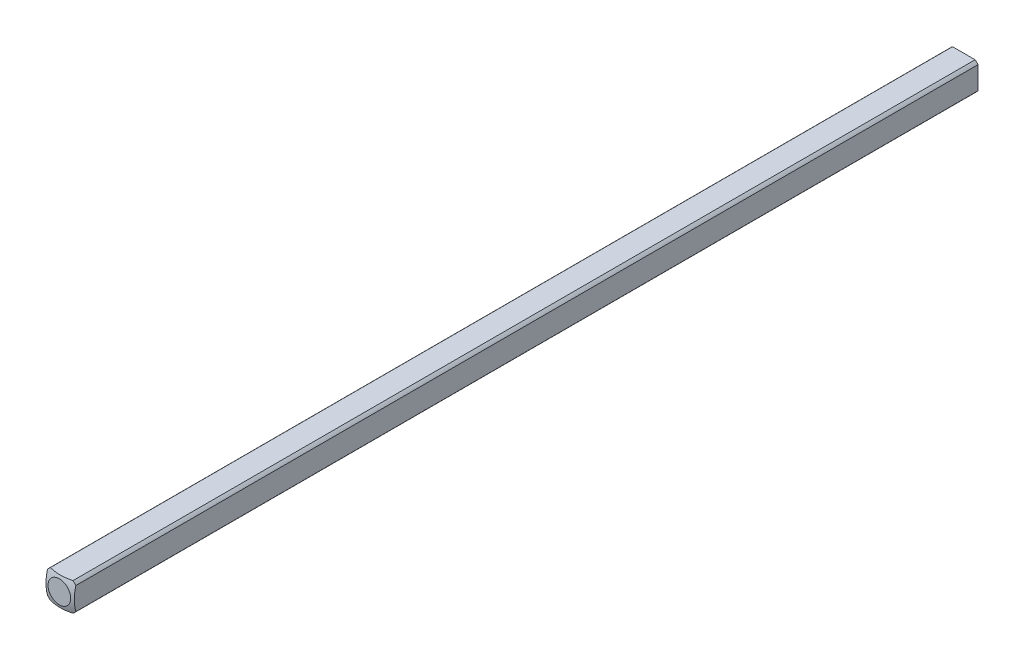
from build123d import *

# Parameters (mm, degrees)
SKETCH1_W           = 3.175
SKETCH1_H           = 3.175
BOSS_EXTRUDE1_DEPTH = 152.4
SKETCH2_OUTSIDE_W   = 35.668
SKETCH2_OUTSIDE_H   = 35.668
SKETCH2_OUTSIDE_R   = 2.032
CUT_EXTRUDE1_DEPTH  = 153.4
CUT_EXTRUDE2_DEPTH  = 4.175


with BuildPart() as part:
    # Sketch1 → Boss-Extrude1 (new body)
    with BuildSketch(Plane.XY):
        Rectangle(SKETCH1_W, SKETCH1_H)
    extrude(amount=BOSS_EXTRUDE1_DEPTH)

    # Sketch2 outside → Cut-Extrude1 (cut, through all)
    with BuildSketch(Plane(origin=(0, 0, 0), x_dir=(-1, 0, 0), z_dir=(0, 0, -1))):
        Rectangle(SKETCH2_OUTSIDE_W, SKETCH2_OUTSIDE_H)
        Circle(SKETCH2_OUTSIDE_R, mode=Mode.SUBTRACT)
    extrude(amount=-CUT_EXTRUDE1_DEPTH, mode=Mode.SUBTRACT)

    # Sketch3 → Cut-Revolve1 (revolve, cut)
    with BuildSketch(Plane(origin=(0, 0, 0), x_dir=(1, 0, 0), z_dir=(0, 1, 0))):
        with BuildLine():
            Line((-5.053685963, -4.40273269), (-5.053685963, 5.740530545))
            Line((-5.053685963, 5.740530545), (0, 5.740530545))
            Line((0, 5.740530545), (0, 0.160877736))
            ThreePointArc((0, 0.160877736), (-3.404639553, -1.148866368), (-5.053685963, -4.40273269))
        make_face()
    revolve(axis=Axis((0, 0, 152.4), (0, 0, -1)), mode=Mode.SUBTRACT)

    # Mirror1: part across plane


with BuildPart() as part_1:
    add(part.part)
    add(part.part.mirror(Plane(origin=(0, 0, 152.4), x_dir=(1, 0, 0), z_dir=(0, 0, -1))))

    # Sketch4 → Cut-Extrude2 (cut, through all)
    with BuildSketch(Plane(origin=(1.5875, 0, 0), x_dir=(0, 0, -1), z_dir=(1, 0, 0))):
        Polygon((-0.263225358, -1.5875), (-203.463225358, -1.5875), (-203.463225358, 1.5875), (-0.263225358, 1.5875), (0.835678169, 1.5875), (0.835678169, -1.5875), align=None)
    extrude(amount=-CUT_EXTRUDE2_DEPTH, mode=Mode.SUBTRACT)


solid = part_1.part
